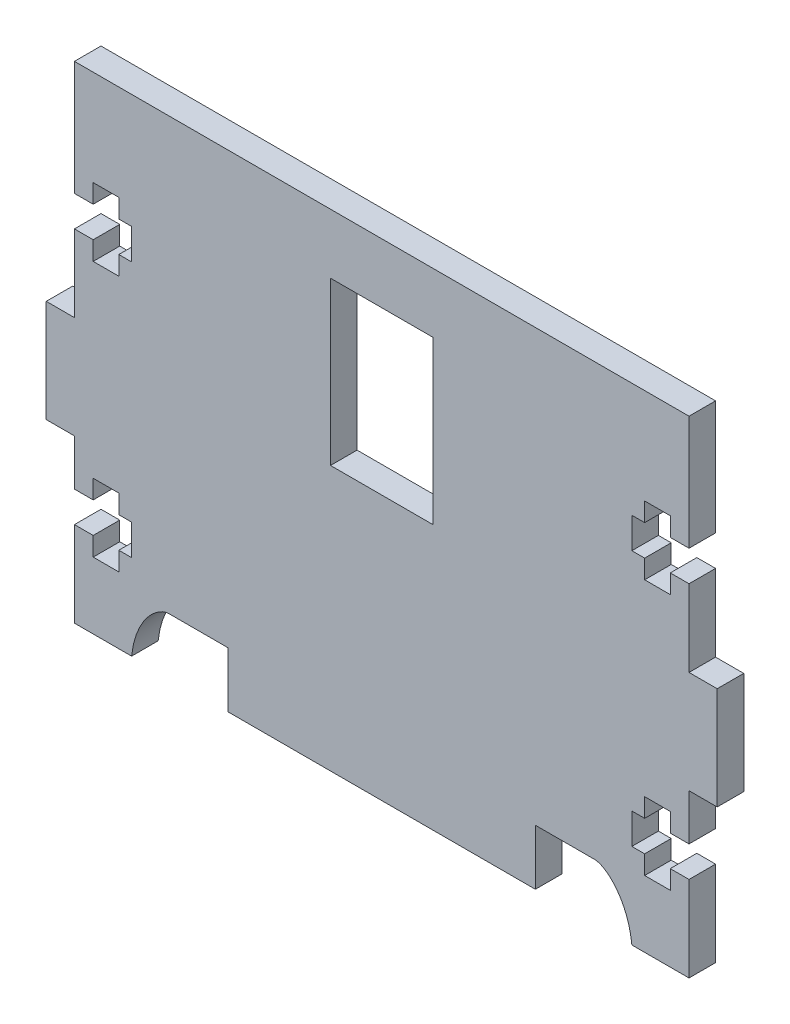
from build123d import *

# Parameters (mm, degrees)
SKETCH2_W           = 12
SKETCH2_H           = 19
BOSS_EXTRUDE1_DEPTH = 3.1115


with BuildPart() as part:
    # Sketch2 → Boss-Extrude1 (new body)
    with BuildSketch(Plane.XY):
        with BuildLine():
            Line((-5.168924328, -39.869822198), (-5.168924328, -33.369822198))
            Line((-5.168924328, -33.369822198), (-12.168924328, -33.369822198))
            add(Edge.make_bspline(
                [(-12.168924328, -33.369822198), (-13.552096669, -33.459867166), (-16.039644903, -35.695120164), (-16.470924328, -39.869822198)],
                knots=[0, 0, 0, 0, 1, 1, 1, 1], degree=3))
            Line((-16.470924328, -39.869822198), (-23.168924328, -39.869822198))
            Line((-23.168924328, -39.869822198), (-23.168924328, -33.469822198))
            Line((-23.168924328, -33.469822198), (-23.168924328, -29.869822198))
            Line((-23.168924328, -29.869822198), (-20.970924328, -29.869822198))
            Line((-20.970924328, -29.869822198), (-20.970924328, -32.069822198))
            Line((-20.970924328, -32.069822198), (-17.970924328, -32.069822198))
            Line((-17.970924328, -32.069822198), (-17.970924328, -29.869822198))
            Line((-17.970924328, -29.869822198), (-16.470924328, -29.869822198))
            Line((-16.470924328, -29.869822198), (-16.470924328, -26.269822198))
            Line((-16.470924328, -26.269822198), (-17.970924328, -26.269822198))
            Line((-17.970924328, -26.269822198), (-17.970924328, -24.069822198))
            Line((-17.970924328, -24.069822198), (-20.970924328, -24.069822198))
            Line((-20.970924328, -24.069822198), (-20.970924328, -26.269822198))
            Line((-20.970924328, -26.269822198), (-23.168924328, -26.269822198))
            Line((-23.168924328, -26.269822198), (-23.168924328, -20.869822198))
            Line((-23.168924328, -20.869822198), (-26.470924328, -20.869822198))
            Line((-26.470924328, -20.869822198), (-26.470924328, -8.869822198))
            Line((-26.470924328, -8.869822198), (-23.168924328, -8.869822198))
            Line((-23.168924328, -8.869822198), (-23.168924328, 0.130177802))
            Line((-23.168924328, 0.130177802), (-20.979823214, 0.130177802))
            Line((-20.979823214, 0.130177802), (-20.970924328, 0.130177802))
            Line((-20.970924328, 0.130177802), (-20.970924328, -2.069822198))
            Line((-20.970924328, -2.069822198), (-17.970924328, -2.069822198))
            Line((-17.970924328, -2.069822198), (-17.970924328, 0.130177802))
            Line((-17.970924328, 0.130177802), (-16.470924328, 0.130177802))
            Line((-16.470924328, 0.130177802), (-16.470924328, 3.730177802))
            Line((-16.470924328, 3.730177802), (-17.970924328, 3.730177802))
            Line((-17.970924328, 3.730177802), (-17.970924328, 5.930177802))
            Line((-17.970924328, 5.930177802), (-20.970924328, 5.930177802))
            Line((-20.970924328, 5.930177802), (-20.970924328, 3.730177802))
            Line((-20.970924328, 3.730177802), (-20.979823214, 3.730177802))
            Line((-20.979823214, 3.730177802), (-23.168924328, 3.730177802))
            Line((-23.168924328, 3.730177802), (-23.168924328, 10.130177802))
            Line((-23.168924328, 10.130177802), (-23.168924328, 17.130177802))
            Line((-23.168924328, 17.130177802), (48.831075672, 17.130177802))
            Line((48.831075672, 17.130177802), (48.831075672, 10.130177802))
            Line((48.831075672, 10.130177802), (48.831075672, 3.730177802))
            Line((48.831075672, 3.730177802), (46.641974559, 3.730177802))
            Line((46.641974559, 3.730177802), (46.633075672, 3.730177802))
            Line((46.633075672, 3.730177802), (46.633075672, 5.930177802))
            Line((46.633075672, 5.930177802), (43.633075672, 5.930177802))
            Line((43.633075672, 5.930177802), (43.633075672, 3.730177802))
            Line((43.633075672, 3.730177802), (42.133075672, 3.730177802))
            Line((42.133075672, 3.730177802), (42.133075672, 0.130177802))
            Line((42.133075672, 0.130177802), (43.633075672, 0.130177802))
            Line((43.633075672, 0.130177802), (43.633075672, -2.069822198))
            Line((43.633075672, -2.069822198), (46.633075672, -2.069822198))
            Line((46.633075672, -2.069822198), (46.633075672, 0.130177802))
            Line((46.633075672, 0.130177802), (46.641974559, 0.130177802))
            Line((46.641974559, 0.130177802), (48.831075672, 0.130177802))
            Line((48.831075672, 0.130177802), (48.831075672, -3.469822198))
            Line((48.831075672, -3.469822198), (48.831075672, -6.869822198))
            Line((48.831075672, -6.869822198), (48.831075672, -8.869822198))
            Line((48.831075672, -8.869822198), (52.133075672, -8.869822198))
            Line((52.133075672, -8.869822198), (52.133075672, -20.869822198))
            Line((52.133075672, -20.869822198), (48.831075672, -20.869822198))
            Line((48.831075672, -20.869822198), (48.831075672, -22.869822198))
            Line((48.831075672, -22.869822198), (48.831075672, -26.269822198))
            Line((48.831075672, -26.269822198), (46.633075672, -26.269822198))
            Line((46.633075672, -26.269822198), (46.633075672, -24.069822198))
            Line((46.633075672, -24.069822198), (43.633075672, -24.069822198))
            Line((43.633075672, -24.069822198), (43.633075672, -26.269822198))
            Line((43.633075672, -26.269822198), (42.133075672, -26.269822198))
            Line((42.133075672, -26.269822198), (42.133075672, -29.869822198))
            Line((42.133075672, -29.869822198), (43.633075672, -29.869822198))
            Line((43.633075672, -29.869822198), (43.633075672, -32.069822198))
            Line((43.633075672, -32.069822198), (46.633075672, -32.069822198))
            Line((46.633075672, -32.069822198), (46.633075672, -29.869822198))
            Line((46.633075672, -29.869822198), (48.831075672, -29.869822198))
            Line((48.831075672, -29.869822198), (48.831075672, -39.869822198))
            Line((48.831075672, -39.869822198), (42.133075672, -39.869822198))
            add(Edge.make_bspline(
                [(37.831075672, -33.369822198), (39.214248014, -33.459867166), (41.701796248, -35.695120164), (42.133075672, -39.869822198)],
                knots=[0, 0, 0, 0, 1, 1, 1, 1], degree=3))
            Line((37.831075672, -33.369822198), (30.831075672, -33.369822198))
            Line((30.831075672, -33.369822198), (30.831075672, -39.869822198))
            Line((30.831075672, -39.869822198), (-5.168924328, -39.869822198))
        make_face()
        with Locations((12.831075672, 0.630177802)):
            Rectangle(SKETCH2_W, SKETCH2_H, mode=Mode.SUBTRACT)
    extrude(amount=BOSS_EXTRUDE1_DEPTH)


solid = part.part
